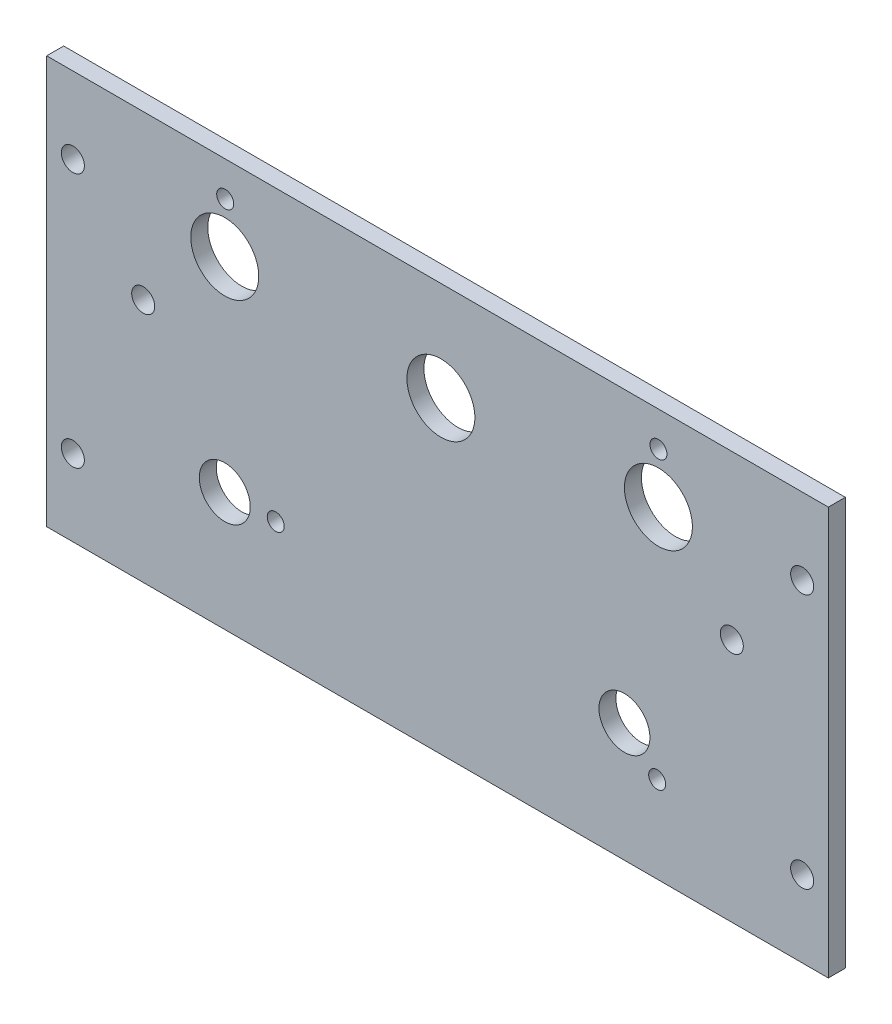
from build123d import *

# Parameters (mm, degrees)
SKETCH1_W                    = 146.05
SKETCH1_H                    = 76.2
BOSS_EXTRUDE1_DEPTH          = 3.175
F_6_CLEARANCE_HOLE1_D        = 4.3053
F_1_2_0_5_DIAMETER_HOLE1_D   = 12.7
F_3_8_0_375_DIAMETER_HOLE1_D = 9.525
F_1_8_0_125_DIAMETER_HOLE1_D = 3.175


with BuildPart() as part:
    # Sketch1 → Boss-Extrude1 (new body)
    with BuildSketch(Plane.XY):
        with Locations((-73.025, 38.1)):
            Rectangle(SKETCH1_W, SKETCH1_H)
    extrude(amount=-BOSS_EXTRUDE1_DEPTH)

    # #6 Clearance Hole1 (through all)
    with Locations(Plane(origin=(0, 0, -3.175), x_dir=(-1, 0, 0), z_dir=(0, 0, -1))):
        with Locations((4.8895, 61.9125), (4.8895, 14.2875), (141.1605, 14.2875), (141.1605, 61.9125), (128.016, 45.72), (18.034, 45.72)):
            Hole(F_6_CLEARANCE_HOLE1_D / 2)

    # 1/2 (0.5) Diameter Hole1 (through all)
    with Locations(Plane(origin=(0, 0, -3.175), x_dir=(-1, 0, 0), z_dir=(0, 0, -1))):
        with Locations((31.75, 60.325), (72.39, 57.658), (112.776, 60.325)):
            Hole(F_1_2_0_5_DIAMETER_HOLE1_D / 2)

    # 3/8 (0.375) Diameter Hole1 (through all)
    with Locations(Plane(origin=(0, 0, -3.175), x_dir=(-1, 0, 0), z_dir=(0, 0, -1))):
        with Locations((38.1, 22.225), (112.776, 22.225)):
            Hole(F_3_8_0_375_DIAMETER_HOLE1_D / 2)

    # 1/8 (0.125) Diameter Hole1 (through all)
    with Locations(Plane(origin=(0, 0, -3.175), x_dir=(-1, 0, 0), z_dir=(0, 0, -1))):
        with Locations((31.75, 69.699492067), (112.695431447, 69.699492067), (103.251, 22.225), (31.98067476, 16.130346764)):
            Hole(F_1_8_0_125_DIAMETER_HOLE1_D / 2)


solid = part.part
